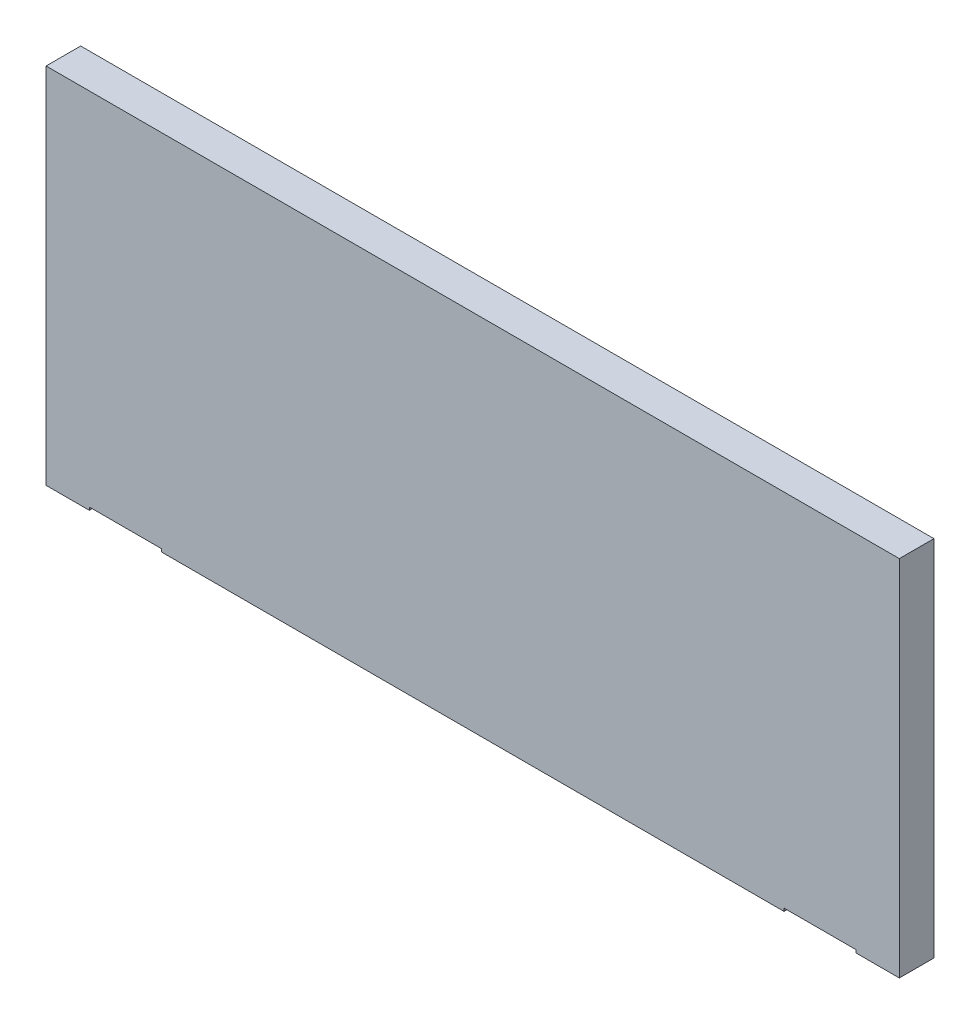
from build123d import *

# Parameters (mm, degrees)
SKETCH1_W           = 296
SKETCH1_H           = 126
BOSS_EXTRUDE1_DEPTH = 12
SKETCH2_R           = 1.5
CUT_EXTRUDE1_DEPTH  = 10
SKETCH3_W           = 25
SKETCH3_H           = 12
CUT_EXTRUDE2_DEPTH  = 1


with BuildPart() as part:
    # Sketch1 → Boss-Extrude1 (new body)
    with BuildSketch(Plane.XY):
        with Locations((148, 63)):
            Rectangle(SKETCH1_W, SKETCH1_H)
    extrude(amount=BOSS_EXTRUDE1_DEPTH)

    # Sketch2 → Cut-Extrude1 (cut)
    with BuildSketch(Plane(origin=(0, 0, 0), x_dir=(1, 0, 0), z_dir=(0, 1, 0))):
        with Locations((21, -6)):
            Circle(SKETCH2_R)
        with Locations((34, -6)):
            Circle(SKETCH2_R)
        with Locations((275, -6)):
            Circle(SKETCH2_R)
        with Locations((262, -6)):
            Circle(SKETCH2_R)
    extrude(amount=CUT_EXTRUDE1_DEPTH, mode=Mode.SUBTRACT)

    # Sketch3 → Cut-Extrude2 (cut)
    with BuildSketch(Plane(origin=(0, 0, 0), x_dir=(1, 0, 0), z_dir=(0, 1, 0))):
        with Locations((27.5, -6)):
            Rectangle(SKETCH3_W, SKETCH3_H)
        with Locations((268.5, -6)):
            Rectangle(SKETCH3_W, SKETCH3_H)
    extrude(amount=CUT_EXTRUDE2_DEPTH, mode=Mode.SUBTRACT)


solid = part.part
